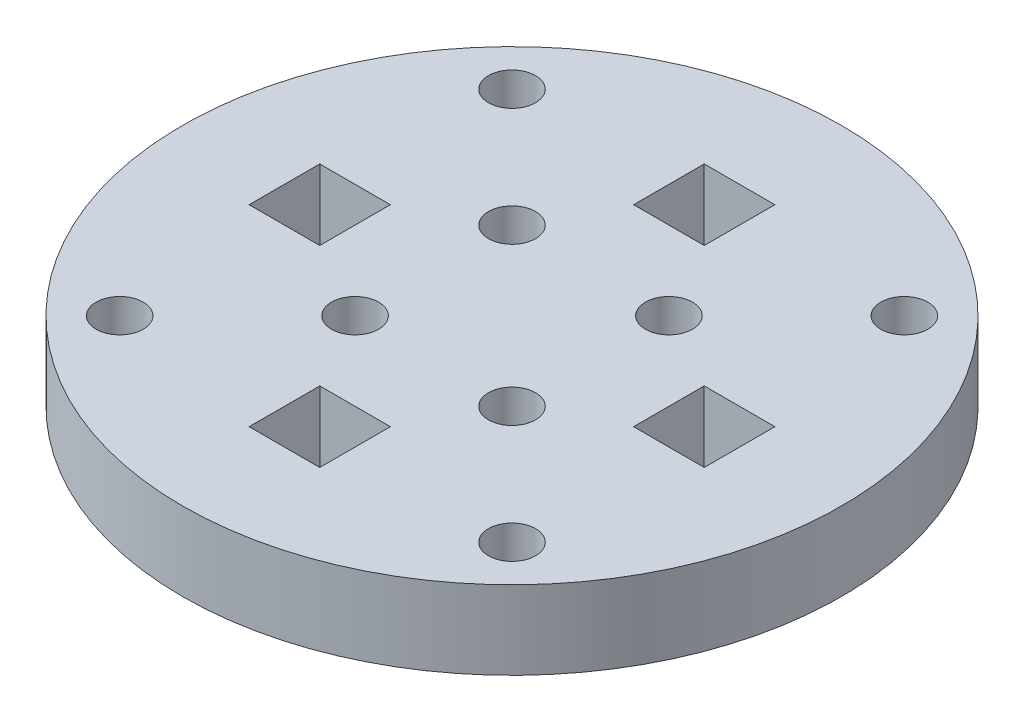
from build123d import *

# Parameters (mm, degrees)
SKETCH1_R           = 21
SKETCH1_R_2         = 1.5
SKETCH1_W           = 4.5
SKETCH1_H           = 4.5
BOSS_EXTRUDE1_DEPTH = 2.5


with BuildPart() as part:
    # Sketch1 → Boss-Extrude1 (new body, symmetric)
    with BuildSketch(Plane(origin=(0, 0, 0), x_dir=(1, 0, 0), z_dir=(0, 1, 0))):
        Circle(SKETCH1_R)
        with Locations((5, 5)):
            Circle(SKETCH1_R_2, mode=Mode.SUBTRACT)
        with Locations((-5, 5)):
            Circle(SKETCH1_R_2, mode=Mode.SUBTRACT)
        with Locations((5, -5)):
            Circle(SKETCH1_R_2, mode=Mode.SUBTRACT)
        with Locations((-5, -5)):
            Circle(SKETCH1_R_2, mode=Mode.SUBTRACT)
        with Locations((-12.5, 12.5)):
            Circle(SKETCH1_R_2, mode=Mode.SUBTRACT)
        with Locations((12.5, 12.5)):
            Circle(SKETCH1_R_2, mode=Mode.SUBTRACT)
        with Locations((12.5, -12.5)):
            Circle(SKETCH1_R_2, mode=Mode.SUBTRACT)
        with Locations((-12.5, -12.5)):
            Circle(SKETCH1_R_2, mode=Mode.SUBTRACT)
        with Locations((12.25, 0)):
            Rectangle(SKETCH1_W, SKETCH1_H, mode=Mode.SUBTRACT)
        with Locations((0, -12.25)):
            Rectangle(SKETCH1_W, SKETCH1_H, mode=Mode.SUBTRACT)
        with Locations((0, 12.25)):
            Rectangle(SKETCH1_W, SKETCH1_H, mode=Mode.SUBTRACT)
        with Locations((-12.25, 0)):
            Rectangle(SKETCH1_W, SKETCH1_H, mode=Mode.SUBTRACT)
    extrude(amount=BOSS_EXTRUDE1_DEPTH, both=True)


solid = part.part
